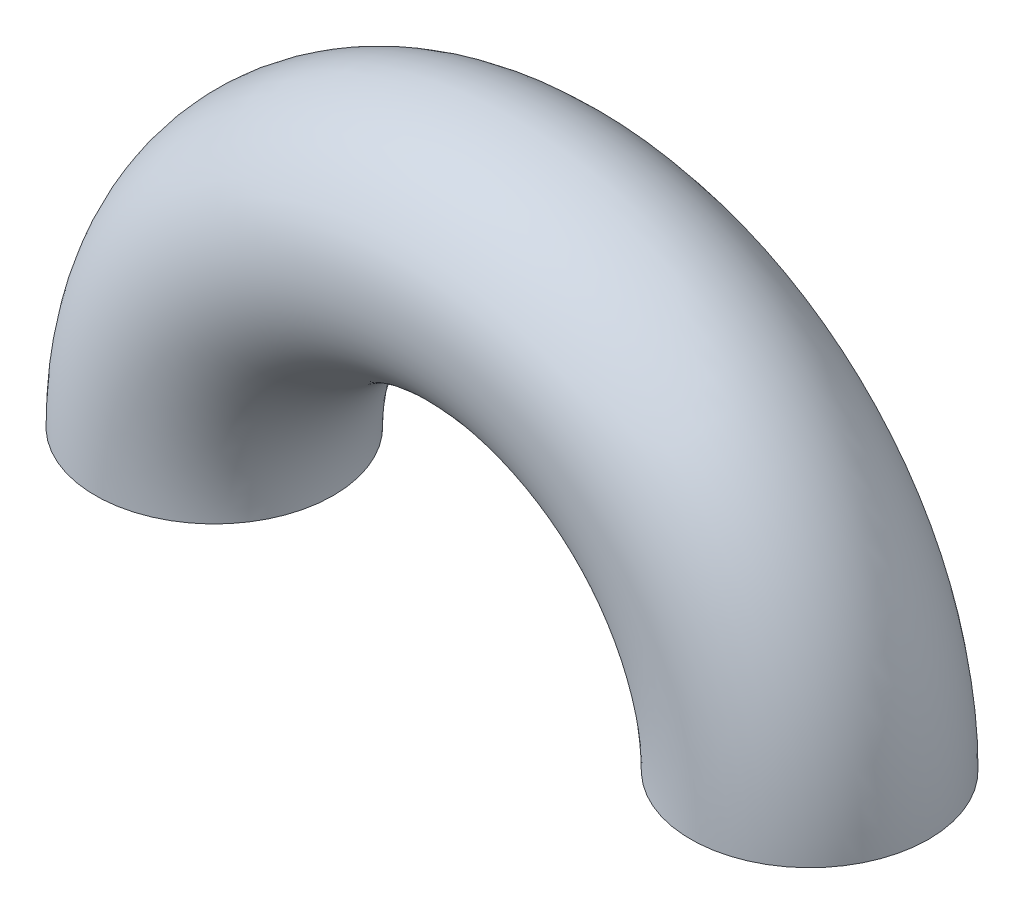
from build123d import *

# Parameters (mm, degrees)
SKETCH2_R = 5
SHELL1_T  = -0.5


with BuildPart() as part:
    # Sweep1: sweep along a path in Sketch1
    with BuildLine(Plane.XY) as sweep1_path:
        ThreePointArc((-12.5, 0), (0, 12.5), (12.5, 0))
    # Sketch2 → Sweep1 (sweep)
    with BuildSketch(Plane(origin=(0, 0, 0), x_dir=(1, 0, 0), z_dir=(0, 1, 0))):
        with Locations((-12.5, 0)):
            Circle(SKETCH2_R)
    sweep(path=sweep1_path.line)

    # Shell1
    shell1_openings = [part.faces().sort_by_distance(p)[0] for p in [
        (12.5, 0, 0),
        (-12.5, 0, 0),
    ]]
    offset(amount=SHELL1_T, openings=shell1_openings, kind=Kind.INTERSECTION)


solid = part.part
